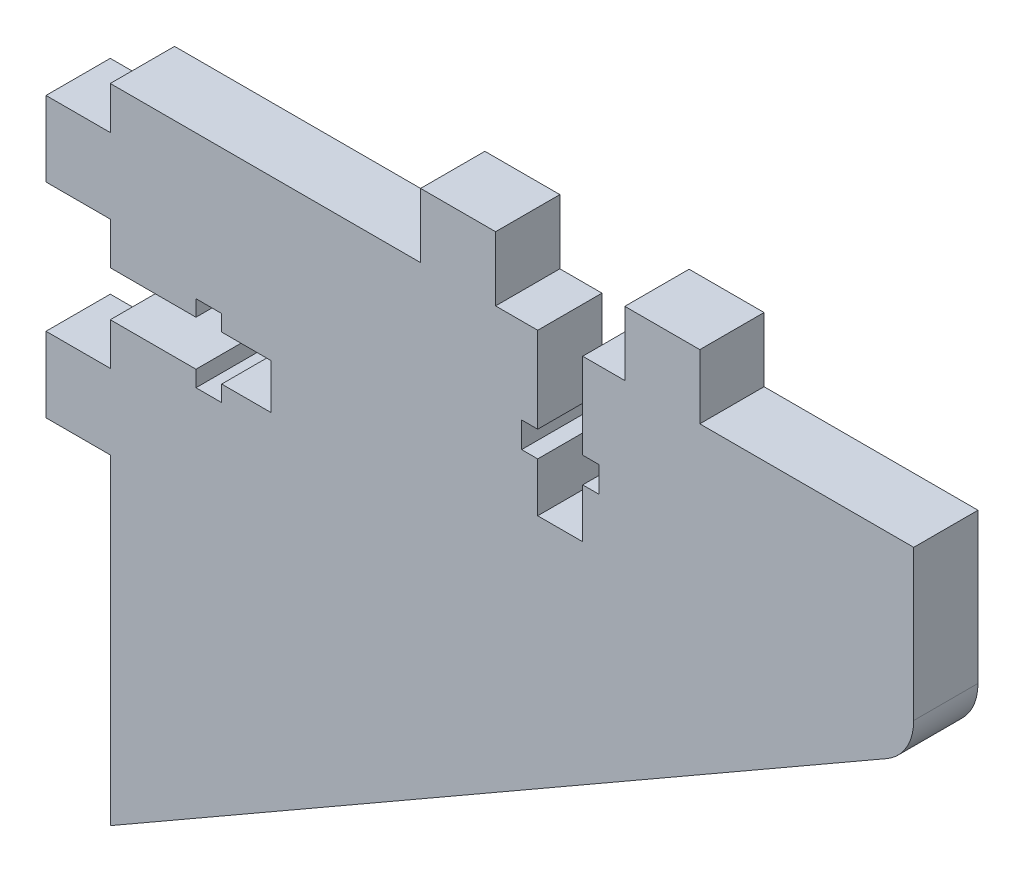
from build123d import *

# Parameters (mm, degrees)
EXTRUDE_1_DEPTH      = 6
SKETCH_2_W           = 7
SKETCH_2_H           = 6
EXTRUDE_2_DEPTH      = 6
CUT_EXTRUDE_1_DEPTH  = 7
SKETCH_21_W          = 7
SKETCH_21_H          = 6
EXTRUDE_21_DEPTH     = 6
CUT_EXTRUDE_11_DEPTH = 7


with BuildPart() as part:
    # Эскиз1 → Бобышка-Вытянуть1 (new body)
    with BuildSketch(Plane.XY):
        with BuildLine():
            Line((81, -293.846153846), (81, -307.846153846))
            ThreePointArc((81, -307.846153846), (80.327690782, -310.350368792), (78.491563001, -312.181141022))
            Line((78.491563001, -312.181141022), (6, -353.846153846))
            Line((6, -353.846153846), (6, -293.846153846))
            Line((6, -293.846153846), (81, -293.846153846))
        make_face()
    extrude(amount=-EXTRUDE_1_DEPTH)

    # Эскиз2 → Бобышка-Вытянуть2 (add)
    with BuildSketch(Plane(origin=(56, -310.846153846, 0), x_dir=(0, 1, 0), z_dir=(0, 0, 1))):
        with Locations((-9.531849908, 53)):
            Rectangle(SKETCH_2_W, SKETCH_2_H)
        with Locations((9.531849908, 53)):
            Rectangle(SKETCH_2_W, SKETCH_2_H)
    extrude(amount=-EXTRUDE_2_DEPTH)

    # Эскиз3 → Вырез-Вытянуть1 (cut, through all)
    with BuildSketch(Plane(origin=(56, -310.846153846, 0), x_dir=(0, 1, 0), z_dir=(0, 0, 1))):
        Polygon((-2.1, 42), (-3.6, 42), (-3.6, 39.6), (-2.1, 39.6), (-2.1, 35), (2.1, 35), (2.1, 39.6), (3.6, 39.6), (3.6, 42), (2.1, 42), (2.1, 50), (-2.1, 50), align=None)
    extrude(amount=-CUT_EXTRUDE_1_DEPTH, mode=Mode.SUBTRACT)

    # Эскиз21 → Бобышка-Вытянуть21 (add)
    with BuildSketch(Plane(origin=(48, -343.846153846, 0), x_dir=(1, 0, 0), z_dir=(0, 0, 1))):
        with Locations((-9.531849908, 53)):
            Rectangle(SKETCH_21_W, SKETCH_21_H)
        with Locations((9.531849908, 53)):
            Rectangle(SKETCH_21_W, SKETCH_21_H)
    extrude(amount=-EXTRUDE_21_DEPTH)

    # Эскиз31 → Вырез-Вытянуть11 (cut, through all)
    with BuildSketch(Plane(origin=(48, -343.846153846, 0), x_dir=(1, 0, 0), z_dir=(0, 0, 1))):
        Polygon((-2.1, 42), (-3.6, 42), (-3.6, 39.6), (-2.1, 39.6), (-2.1, 35), (2.1, 35), (2.1, 39.6), (3.6, 39.6), (3.6, 42), (2.1, 42), (2.1, 50), (-2.1, 50), align=None)
    extrude(amount=-CUT_EXTRUDE_11_DEPTH, mode=Mode.SUBTRACT)


solid = part.part
